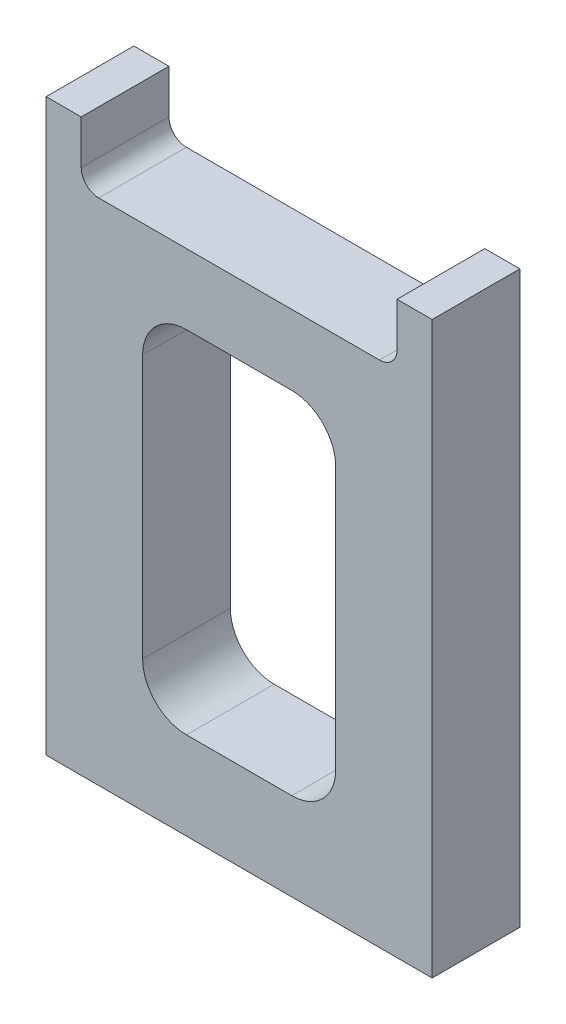
from build123d import *

# Parameters (mm, degrees)
BOSS_EXTRUDE1_DEPTH = 10
SKETCH2_R           = 2
CUT_EXTRUDE1_DEPTH  = 10
FILLET1_R           = 2
SKETCH3_W           = 22
SKETCH3_H           = 40
CUT_EXTRUDE2_DEPTH  = 11
FILLET2_R           = 5


with BuildPart() as part:
    # Sketch1 → Boss-Extrude1 (new body)
    with BuildSketch(Plane.XY):
        Polygon((-22, 0), (22, 0), (22, 65), (18, 65), (18, 58), (-18, 58), (-18, 65), (-22, 65), align=None)
    extrude(amount=BOSS_EXTRUDE1_DEPTH)

    # Sketch2 → Cut-Extrude1 (cut)
    with BuildSketch(Plane.XZ):
        with Locations((15, 5)):
            Circle(SKETCH2_R)
        with Locations((-15, 5)):
            Circle(SKETCH2_R)
    extrude(amount=-CUT_EXTRUDE1_DEPTH, mode=Mode.SUBTRACT)

    # Fillet1
    fillet1_edges = [part.edges().sort_by_distance(p)[0] for p in [
        (-18, 58, 5),
        (18, 58, 5),
    ]]
    fillet(fillet1_edges, radius=FILLET1_R)

    # Sketch3 → Cut-Extrude2 (cut, through all)
    with BuildSketch(Plane(origin=(0, 0, 0), x_dir=(-1, 0, 0), z_dir=(0, 0, -1))):
        with Locations((0, 30)):
            Rectangle(SKETCH3_W, SKETCH3_H)
    extrude(amount=-CUT_EXTRUDE2_DEPTH, mode=Mode.SUBTRACT)

    # Fillet2
    fillet2_edges = [part.edges().sort_by_distance(p)[0] for p in [
        (11, 10, 5),
        (11, 50, 5),
        (-11, 50, 5),
        (-11, 10, 5),
    ]]
    fillet(fillet2_edges, radius=FILLET2_R)


solid = part.part
